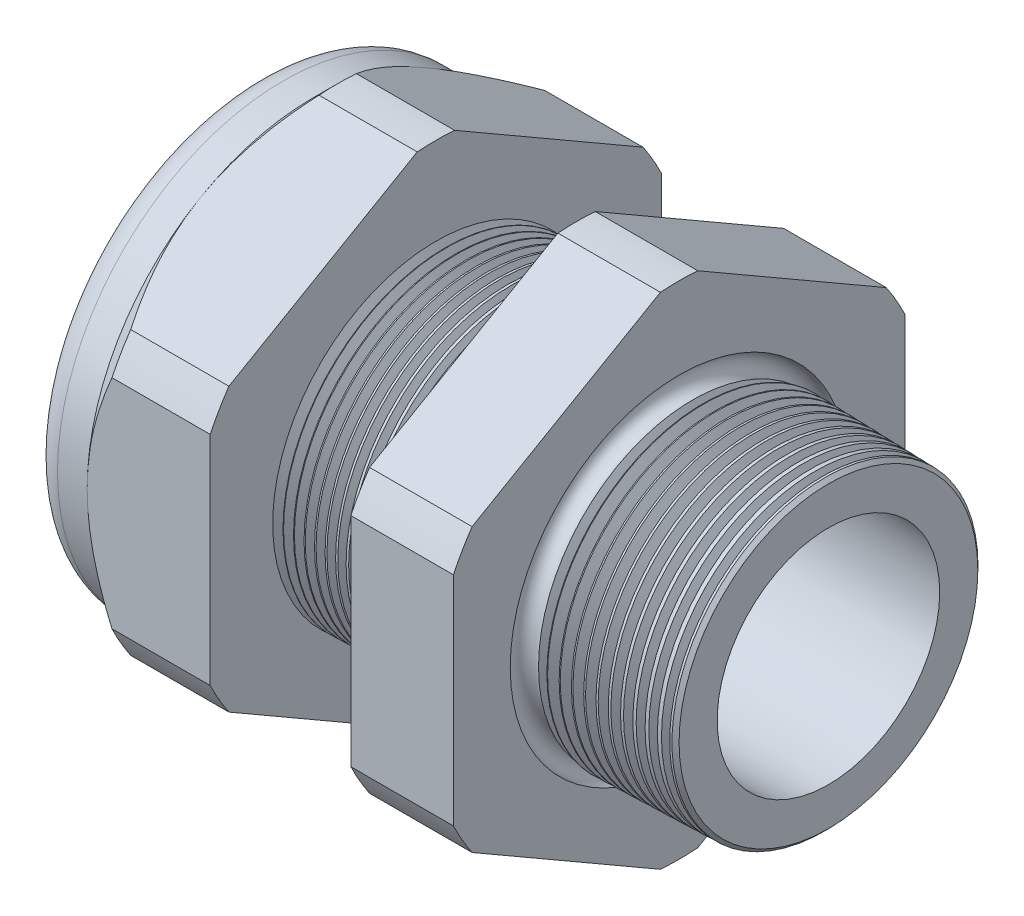
from build123d import *

# Parameters (mm, degrees)
SKETCH12_OUTSIDE_W = 88.514
SKETCH12_OUTSIDE_H = 88.514
CUT_EXTRUDE2_DEPTH = 38.71
FILLET4_R          = 2.032
SKETCH19_OUTSIDE_W = 55.962
SKETCH19_OUTSIDE_H = 59.594
SKETCH19_OUTSIDE_R = 16.51
CUT_EXTRUDE3_DEPTH = 3.99796
CUT_EXTRUDE3_DRAFT = -45
CHAMFER1_SIZE      = 0.260919487
CHAMFER1_SIZE2     = 0.254
SKETCH21_R         = 9.017
PLUG_DEPTH         = 8.89
SKETCH22_R         = 8.763
CUT_EXTRUDE4_DEPTH = 0.508
SKETCH27_R         = 3.556
PLUGHOLES_DEPTH    = 42.402
CIRPATTERN1_COUNT  = 3
LPATTERN1_COUNT    = 14
LPATTERN1_PITCH    = 0.762
LPATTERN2_COUNT    = 12
LPATTERN2_PITCH    = 0.889
SKETCH32_R         = 0.889


with BuildPart() as part:
    # Sketch10 → Revolve2 (revolve)
    with BuildSketch(Plane.XY, mode=Mode.PRIVATE) as revolve2_sk:
        Polygon((-38.862, 9.017), (-25.662, 9.017), (3.048, 8.138202192), (3.048, 11.186202192), (-7.874, 11.472204827), (-7.874, 33.02), (-15.374, 33.02), (-15.374, 11.668599239), (-25.662, 11.938), (-25.662, 33.02), (-34.662, 33.02), (-34.662, 16.51), (-38.862, 16.51), align=None)
    revolve(revolve2_sk.sketch.rotate(Axis((0, 0, 0), (-1, 0, 0)), 90), axis=Axis((0, 0, 0), (-1, 0, 0)))  # turned: the seam where the file's is

    # Sketch12 outside → Cut-Extrude2 (cut, through all)
    with BuildSketch(Plane.ZY.offset(34.662)):
        Rectangle(SKETCH12_OUTSIDE_W, SKETCH12_OUTSIDE_H)
        with BuildLine():
            Line((-1.366648898, 18.27507078), (-15.143351102, 10.321088053))
            ThreePointArc((-15.143351102, 10.321088053), (-15.870868152, 9.16305), (-16.51, 7.953982726))
            Line((-16.51, 7.953982726), (-16.51, -7.953982726))
            ThreePointArc((-16.51, -7.953982726), (-15.870868152, -9.16305), (-15.143351102, -10.321088053))
            Line((-15.143351102, -10.321088053), (-1.366648898, -18.27507078))
            ThreePointArc((-1.366648898, -18.27507078), (0, -18.3261), (1.366648898, -18.27507078))
            Line((1.366648898, -18.27507078), (15.143351102, -10.321088053))
            ThreePointArc((15.143351102, -10.321088053), (15.870868152, -9.16305), (16.51, -7.953982726))
            Line((16.51, -7.953982726), (16.51, 7.953982726))
            ThreePointArc((16.51, 7.953982726), (15.870868152, 9.16305), (15.143351102, 10.321088053))
            Line((15.143351102, 10.321088053), (1.366648898, 18.27507078))
            ThreePointArc((1.366648898, 18.27507078), (0, 18.3261), (-1.366648898, 18.27507078))
        make_face(mode=Mode.SUBTRACT)
    extrude(amount=-CUT_EXTRUDE2_DEPTH, mode=Mode.SUBTRACT)

    # Fillet4
    fillet4_edges = [part.edges().sort_by_distance(p)[0] for p in [
        (-38.862, 0, 16.51),
    ]]
    fillet(fillet4_edges, radius=FILLET4_R)


with BuildPart() as cut_extrude3_tool:
    # Sketch19 outside → Cut-Extrude3 (with draft: the straight prism first)
    with BuildSketch(Plane.ZY.offset(34.662)):
        Rectangle(SKETCH19_OUTSIDE_W, SKETCH19_OUTSIDE_H)
        Circle(SKETCH19_OUTSIDE_R, mode=Mode.SUBTRACT)
    extrude(amount=-CUT_EXTRUDE3_DEPTH)
    # Cut-Extrude3: the draft: its side faces are tilted about the plane it starts from
    cut_extrude3_sides = [cut_extrude3_tool.faces().sort_by_distance(p)[0] for p in [
        (-32.66302, -29.797, 0),
        (-32.66302, 0, 27.981),
        (-32.66302, 29.797, 0),
        (-32.66302, 0, -27.981),
        (-32.66302, 0, -16.51),
    ]]
    draft(cut_extrude3_sides, Plane.ZY.offset(34.662), CUT_EXTRUDE3_DRAFT)


with BuildPart() as part_1:
    add(part.part)

    # Cut-Extrude3: cut by cut_extrude3_tool
    add(cut_extrude3_tool.part, mode=Mode.SUBTRACT)

    # Chamfer1
    chamfer1_edges = [part_1.edges().sort_by_distance(p)[0] for p in [
        (3.048, 0, 11.186202192),
    ]]
    chamfer1_side = [part_1.faces().sort_by_distance(p)[0] for p in [
        (3.048, 0, 8.454595769),
    ]]
    chamfer(chamfer1_edges, length=CHAMFER1_SIZE, length2=CHAMFER1_SIZE2, reference=chamfer1_side[0])

    # Sketch29 → Cut-Revolve1 (revolve, cut)
    with BuildSketch(Plane.XY, mode=Mode.PRIVATE) as cut_revolve1_sk:
        Polygon((-25.662, 11.938), (-24.929016419, 11.918806149), (-25.312130572, 11.293620673), align=None)
    cut_revolve1 = revolve(cut_revolve1_sk.sketch.rotate(Axis((0, 0, 0), (-1, 0, 0)), 90), axis=Axis((0, 0, 0), (-1, 0, 0)), mode=Mode.SUBTRACT)  # turned: the seam where the file's is

    # LPattern1: Cut-Revolve1 ×14
    with Locations(*[(i * LPATTERN1_PITCH, 0, 0) for i in range(1, LPATTERN1_COUNT)]):
        add(cut_revolve1, mode=Mode.SUBTRACT)

    # Sketch30 → Cut-Revolve2 (revolve, cut)
    with BuildSketch(Plane.XY, mode=Mode.PRIVATE) as cut_revolve2_sk:
        Polygon((-7.874, 11.472204827), (-6.994419703, 11.449172206), (-7.454156686, 10.698949635), align=None)
    cut_revolve2 = revolve(cut_revolve2_sk.sketch.rotate(Axis((0, 0, 0), (-1, 0, 0)), 270), axis=Axis((0, 0, 0), (-1, 0, 0)), mode=Mode.SUBTRACT)  # turned: the seam where the file's is

    # LPattern2: Cut-Revolve2 ×12
    with Locations(*[(i * LPATTERN2_PITCH, 0, 0) for i in range(1, LPATTERN2_COUNT)]):
        add(cut_revolve2, mode=Mode.SUBTRACT)

    # Sketch32 → Cut-Revolve3 (revolve, cut)
    with BuildSketch(Plane.XY, mode=Mode.PRIVATE) as cut_revolve3_sk:
        with Locations((-7.747, 11.472204827)):
            Circle(SKETCH32_R)
    revolve(cut_revolve3_sk.sketch.rotate(Axis((0, 0, 0), (-1, 0, 0)), 270), axis=Axis((0, 0, 0), (-1, 0, 0)), mode=Mode.SUBTRACT)  # turned: the seam where the file's is


with BuildPart() as body_2:
    # Sketch21 → plug (new body)
    with BuildSketch(Plane.ZY.offset(38.862)):
        Circle(SKETCH21_R)
    extrude(amount=-PLUG_DEPTH)

    # Sketch22 → Cut-Extrude4 (cut)
    with BuildSketch(Plane.ZY.offset(38.862)):
        Circle(SKETCH22_R)
    extrude(amount=-CUT_EXTRUDE4_DEPTH, mode=Mode.SUBTRACT)

    # Sketch27 → plugholes (cut, through all)
    with BuildSketch(Plane.ZY.offset(38.354)):
        with Locations((-5.192776, 0)):
            Circle(SKETCH27_R)
    plugholes = extrude(amount=-PLUGHOLES_DEPTH, mode=Mode.SUBTRACT)

    # CirPattern1: plugholes ×3 about axis
    cirpattern1_axis = Axis((0, 0, 0), (1, 0, 0))
    for i in range(1, CIRPATTERN1_COUNT):
        add(plugholes.rotate(cirpattern1_axis, i * 360 / CIRPATTERN1_COUNT), mode=Mode.SUBTRACT)


solid = Compound([part_1.part, body_2.part])
